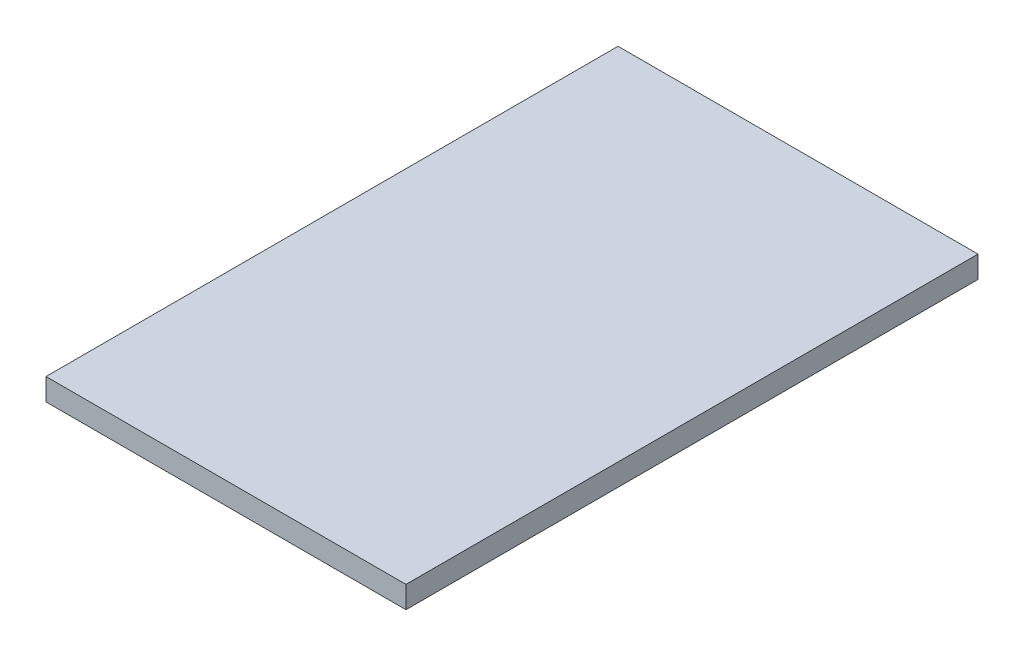
from build123d import *

# Parameters (mm, degrees)
SKETCH1_W           = 26.2128
SKETCH1_H           = 41.656
BOSS_EXTRUDE1_DEPTH = 1.6002


with BuildPart() as part:
    # Sketch1 → Boss-Extrude1 (new body)
    with BuildSketch(Plane(origin=(0, 0, 0), x_dir=(1, 0, 0), z_dir=(0, 1, 0))):
        with Locations((13.1064, 20.828)):
            Rectangle(SKETCH1_W, SKETCH1_H)
    extrude(amount=BOSS_EXTRUDE1_DEPTH)


solid = part.part
